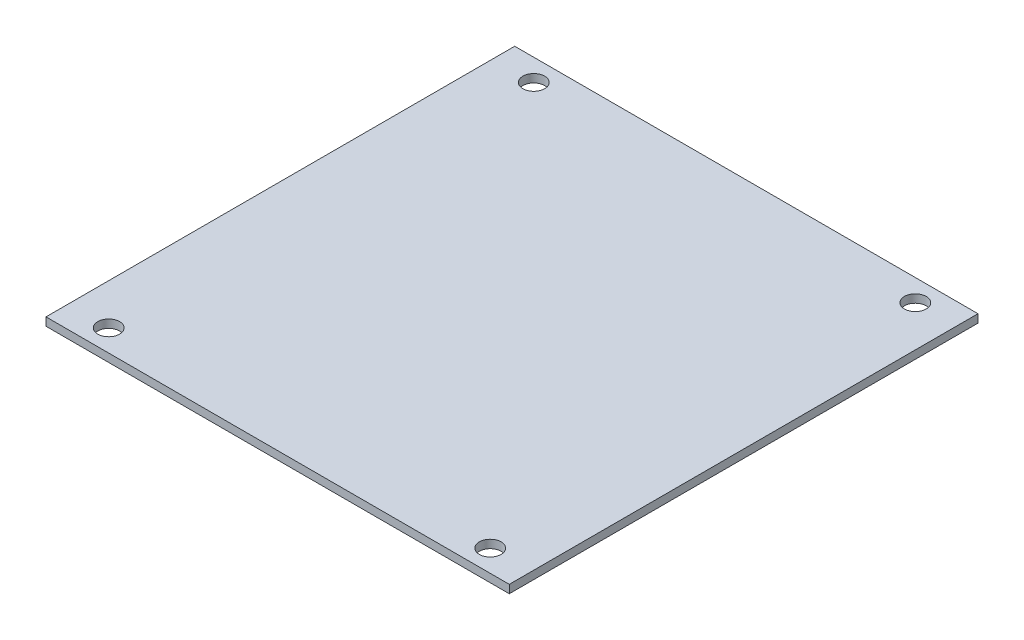
from build123d import *

# Parameters (mm, degrees)
SKETCH1_W           = 170
SKETCH1_H           = 172
SKETCH1_R           = 4
BOSS_EXTRUDE1_DEPTH = 3


with BuildPart() as part:
    # Sketch1 → Boss-Extrude1 (new body)
    with BuildSketch(Plane(origin=(0, 0, 0), x_dir=(1, 0, 0), z_dir=(0, 1, 0))):
        Rectangle(SKETCH1_W, SKETCH1_H)
        with Locations((-70, 78)):
            Circle(SKETCH1_R, mode=Mode.SUBTRACT)
        with Locations((70, 78)):
            Circle(SKETCH1_R, mode=Mode.SUBTRACT)
        with Locations((70, -78)):
            Circle(SKETCH1_R, mode=Mode.SUBTRACT)
        with Locations((-70, -78)):
            Circle(SKETCH1_R, mode=Mode.SUBTRACT)
    extrude(amount=BOSS_EXTRUDE1_DEPTH)


solid = part.part
